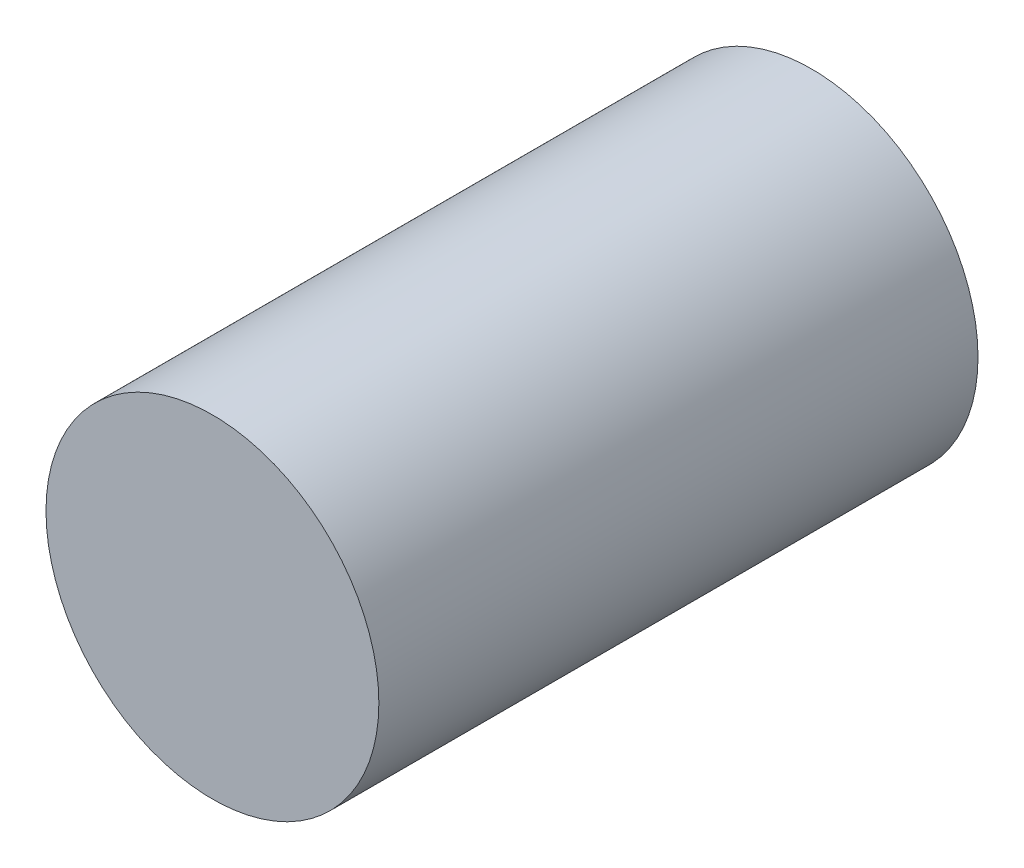
from build123d import *

# Parameters (mm, degrees)
CROQUIS1_R              = 5
SALIENTE_EXTRUIR1_DEPTH = 18


with BuildPart() as part:
    # Croquis1 → Saliente-Extruir1 (new body)
    with BuildSketch(Plane.XY):
        Circle(CROQUIS1_R)
    extrude(amount=SALIENTE_EXTRUIR1_DEPTH)


solid = part.part
